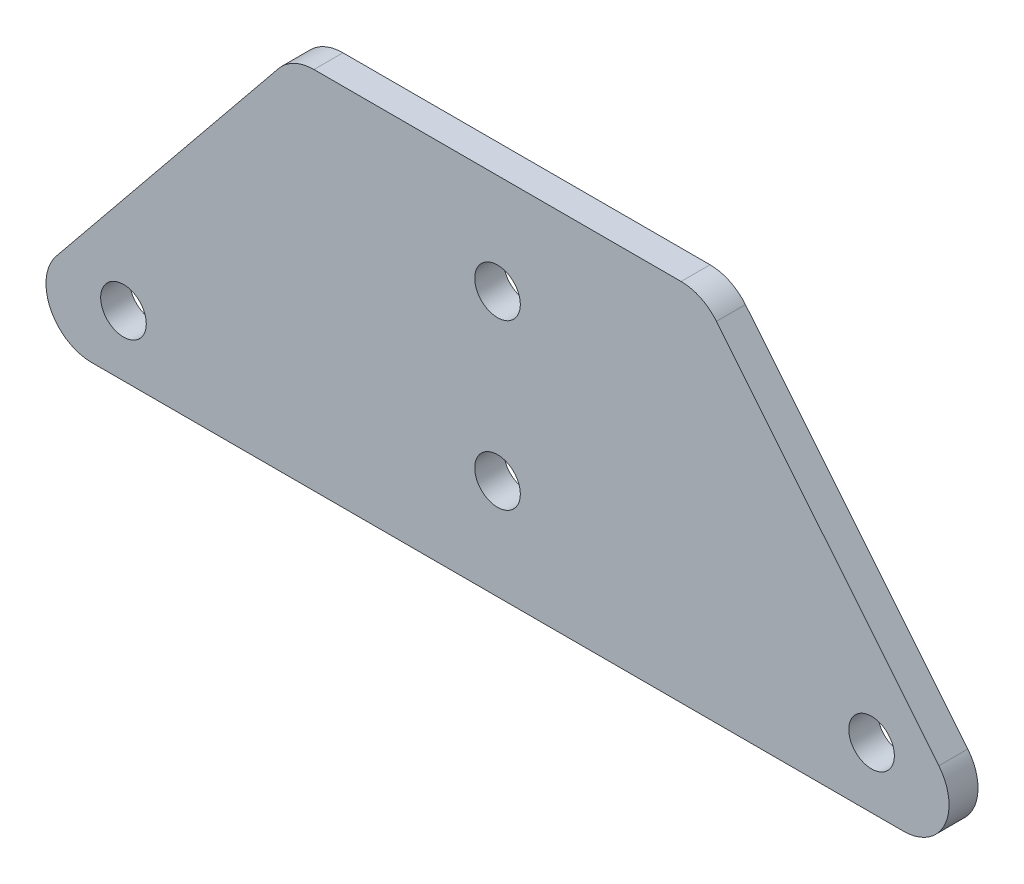
from build123d import *

# Parameters (mm, degrees)
SKETCH1_R           = 2.5
BOSS_EXTRUDE1_DEPTH = 3.175


with BuildPart() as part:
    # Sketch1 → Boss-Extrude1 (new body)
    with BuildSketch(Plane.XY):
        with BuildLine():
            Line((-44.49514746, -23.152963125), (44.49514746, -23.152963125))
            ThreePointArc((44.49514746, -23.152963125), (49.009835468, -20.30182147), (48.375717461, -15))
            Line((48.375717461, -15), (24.000717461, 15))
            ThreePointArc((24.000717461, 15), (22.269005805, 16.361724883), (20.12014746, 16.847036875))
            Line((20.12014746, 16.847036875), (-20.12014746, 16.847036875))
            ThreePointArc((-20.12014746, 16.847036875), (-22.269005805, 16.361724883), (-24.000717461, 15))
            Line((-24.000717461, 15), (-48.375717461, -15))
            ThreePointArc((-48.375717461, -15), (-49.009835468, -20.30182147), (-44.49514746, -23.152963125))
        make_face()
        with Locations((0, 5.847036875)):
            Circle(SKETCH1_R, mode=Mode.SUBTRACT)
        with Locations((0, -12.152963125)):
            Circle(SKETCH1_R, mode=Mode.SUBTRACT)
        with Locations((-41, -16.489376013)):
            Circle(SKETCH1_R, mode=Mode.SUBTRACT)
        with Locations((41, -16.489376013)):
            Circle(SKETCH1_R, mode=Mode.SUBTRACT)
    extrude(amount=BOSS_EXTRUDE1_DEPTH)


solid = part.part
